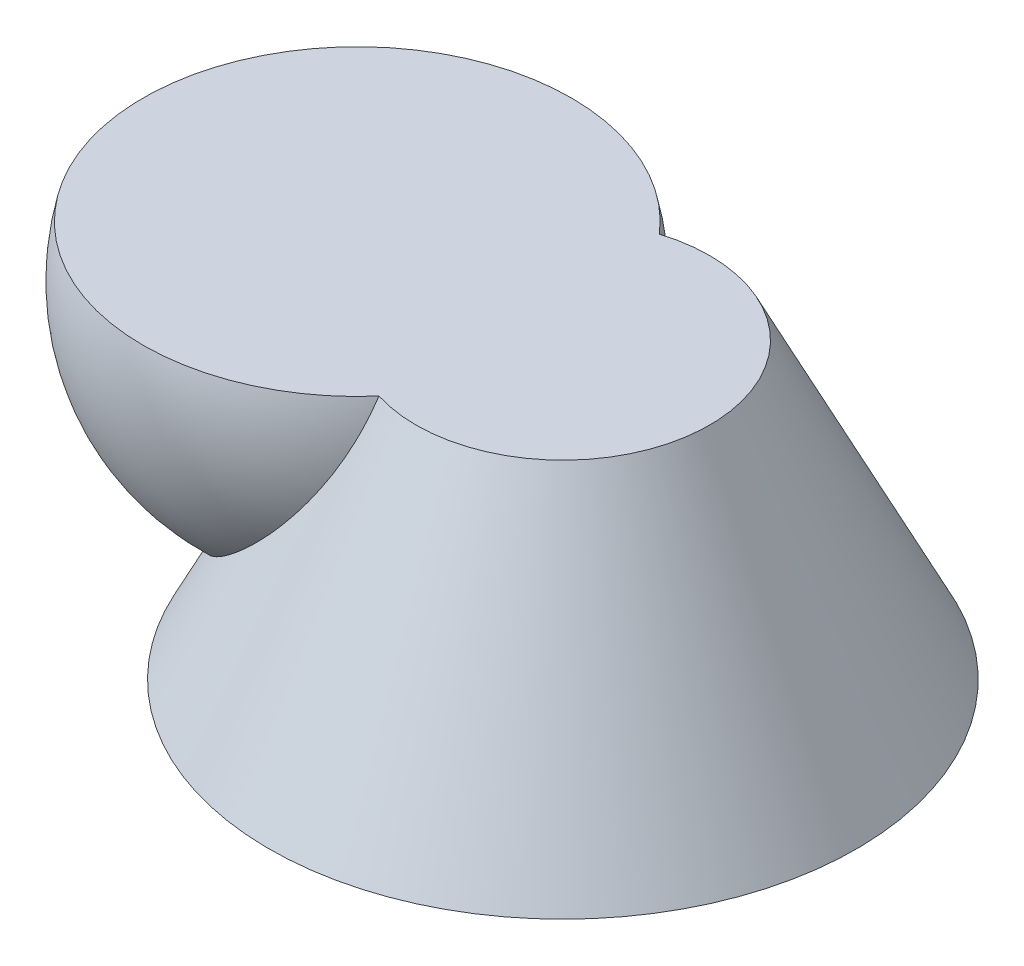
from build123d import *


with BuildPart() as part:
    # Sketch1 → Revolve1 (revolve)
    with BuildSketch(Plane.XY):
        with BuildLine():
            Line((0, 3), (0, 63))
            ThreePointArc((0, 63), (-30, 33), (0, 3))
        make_face()
    revolve(axis=Axis((0, 3, 0), (0, 1, 0)))

    # Sketch2 → Revolve2 (revolve)
    with BuildSketch(Plane.XY, mode=Mode.PRIVATE) as revolve2_sk:
        Polygon((-12, 0), (28, 80), (28, 0), align=None)
    revolve(revolve2_sk.sketch.rotate(Axis((28, 80, 0), (0, -1, 0)), 180), axis=Axis((28, 80, 0), (0, -1, 0)))  # turned: the seam where the file's is

    # SurfaceCut1
    split(bisect_by=Plane(origin=(0, 40, 0), x_dir=(1, 0, 0), z_dir=(0, 1, 0)), keep=Keep.BOTTOM)


solid = part.part
